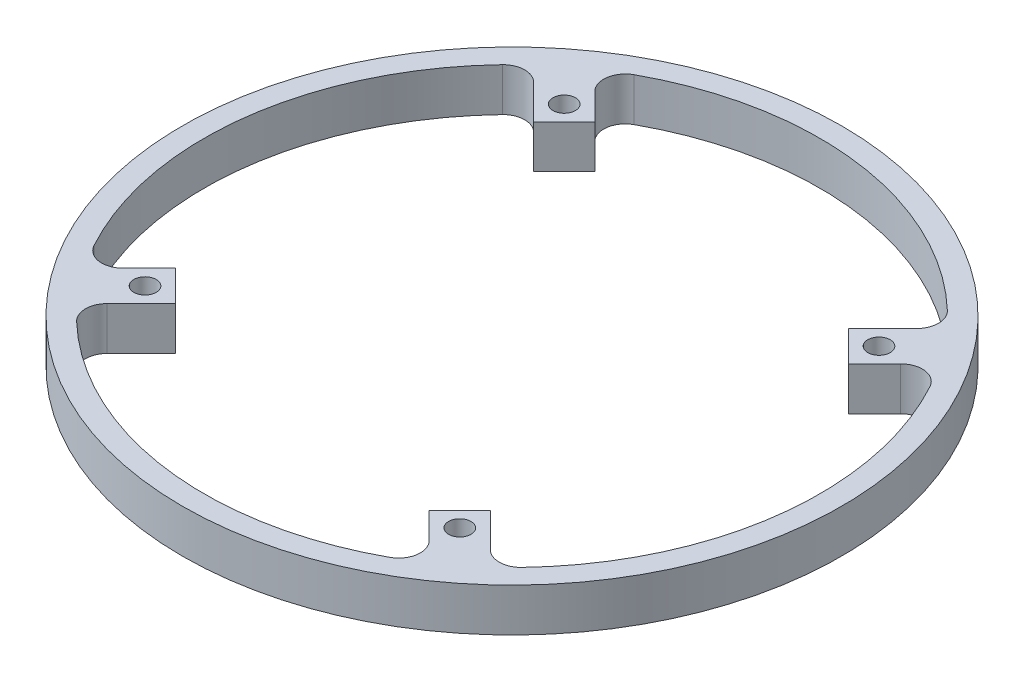
from build123d import *

# Parameters (mm, degrees)
SKETCH2_W                  = 21.2
SKETCH2_H                  = 10
F_6_0_204_DIAMETER_HOLE1_D = 5.1816
CUT_EXTRUDE1_DEPTH         = 11
CIRPATTERN1_COUNT          = 4
FILLET1_R                  = 5


with BuildPart() as part:
    # Sketch2 → Revolve1 (revolve)
    with BuildSketch(Plane(origin=(0, 0, 0), x_dir=(0, 0, -1), z_dir=(1, 0, 0))):
        with Locations((-65.6, 5)):
            Rectangle(SKETCH2_W, SKETCH2_H)
    revolve(axis=Axis((0, 3.678923398, 0), (0, 1, 0)))

    # #6 (0.204) Diameter Hole1 (through all)
    with Locations(Plane(origin=(0, 0, 0), x_dir=(-1, 0, 0), z_dir=(0, -1, 0))):
        with Locations((36.390872965, 48.461940777)):
            f_6_0_204_diameter_hole1 = Hole(F_6_0_204_DIAMETER_HOLE1_D / 2)

    # Sketch14 → Cut-Extrude1 (cut, through all)
    with BuildSketch(Plane.XZ):
        with BuildLine():
            Line((-33.070789849, -38.070789849), (-47.783894042, -52.783894042))
            ThreePointArc((-47.783894042, -52.783894042), (-70.683932228, -8.55696937), (-58.998941132, 39.856805508))
            Line((-58.998941132, 39.856805508), (-55.533008589, 36.390872965))
            Line((-55.533008589, 36.390872965), (-48.461940777, 29.319805153))
            Line((-48.461940777, 29.319805153), (-41.390872965, 36.390872965))
            Line((-41.390872965, 36.390872965), (-38.070789849, 33.070789849))
            ThreePointArc((-38.070789849, 33.070789849), (-50.304693428, -3.535533906), (-33.070789849, -38.070789849))
        make_face()
    cut_extrude1 = extrude(amount=-CUT_EXTRUDE1_DEPTH, mode=Mode.SUBTRACT)

    # CirPattern1: #6 (0.204) Diameter Hole1, Cut-Extrude1 ×4 about axis
    cirpattern1_axis = Axis((0, 0, 0), (0, 1, 0))
    for i in range(1, CIRPATTERN1_COUNT):
        add(f_6_0_204_diameter_hole1.rotate(cirpattern1_axis, i * 360 / CIRPATTERN1_COUNT), mode=Mode.SUBTRACT)
        add(cut_extrude1.rotate(cirpattern1_axis, i * 360 / CIRPATTERN1_COUNT), mode=Mode.SUBTRACT)

    # Fillet1
    fillet1_edges = [part.edges().sort_by_distance(p)[0] for p in [
        (-47.783894042, 5, -52.783894042),
        (-58.998941132, 5, 39.856805508),
        (-52.783894042, 5, 47.783894042),
        (39.856805508, 5, 58.998941132),
        (47.783894042, 5, 52.783894042),
        (58.998941132, 5, -39.856805508),
        (52.783894042, 5, -47.783894042),
        (-39.856805508, 5, -58.998941132),
    ]]
    fillet(fillet1_edges, radius=FILLET1_R)


solid = part.part
